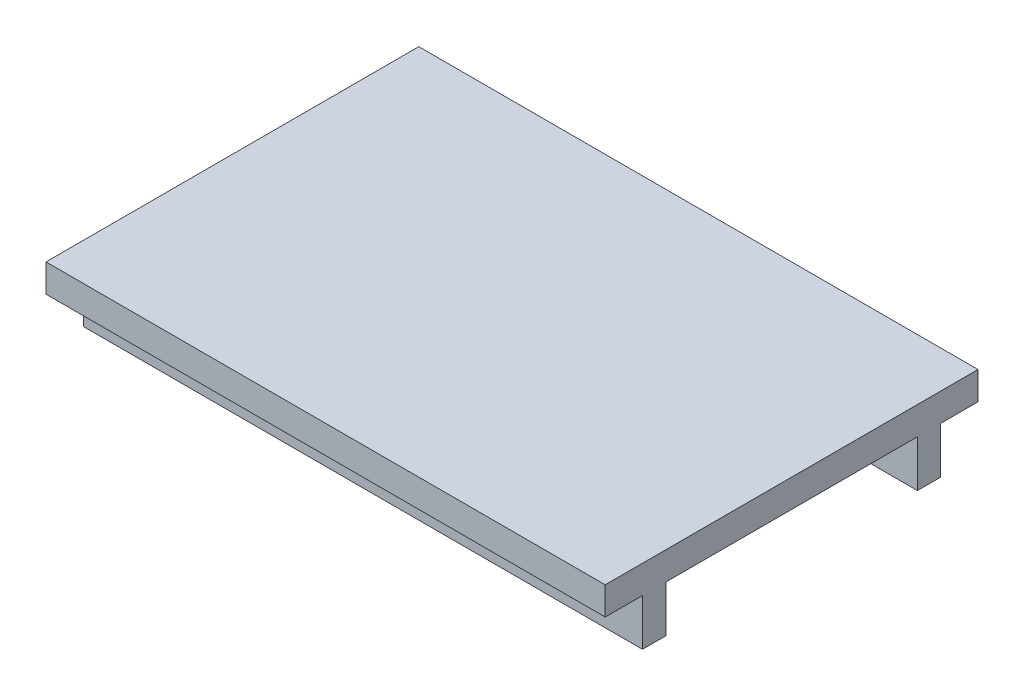
from build123d import *

# Parameters (mm, degrees)
SKETCH_1_W          = 120
SKETCH_1_H          = 80
EXTRUDE_1_DEPTH     = 6
SKETCH_10_W         = 120
SKETCH_10_H         = 5
EXTRUDE_3_DEPTH     = 10
SKETCH_11_R         = 2.5
CUT_EXTRUDE_1_DEPTH = 5


with BuildPart() as part:
    # 草圖1 → 填料-伸長1 (new body)
    with BuildSketch(Plane(origin=(0, 0, 0), x_dir=(1, 0, 0), z_dir=(0, 1, 0))):
        Rectangle(SKETCH_1_W, SKETCH_1_H)
    extrude(amount=EXTRUDE_1_DEPTH)

    # 草圖10 → 填料-伸長3 (add)
    with BuildSketch(Plane.XZ):
        with Locations((0, 29.5)):
            Rectangle(SKETCH_10_W, SKETCH_10_H)
    extrude_3 = extrude(amount=EXTRUDE_3_DEPTH)

    # 草圖11 → 除料-伸長1 (cut)
    with BuildSketch(Plane.XY.offset(32)):
        with Locations((-45, -5)):
            Circle(SKETCH_11_R)
        with BuildLine():
            Line((-20, -2.5), (50, -2.5))
            ThreePointArc((50, -2.5), (52.5, -5), (50, -7.5))
            Line((50, -7.5), (-20, -7.5))
            ThreePointArc((-20, -7.5), (-22.5, -5), (-20, -2.5))
        make_face()
    cut_extrude_1 = extrude(amount=-CUT_EXTRUDE_1_DEPTH, mode=Mode.SUBTRACT)

    # 鏡射3: 填料-伸長3, 除料-伸長1 across plane
    add(extrude_3.mirror(Plane.XY))
    add(cut_extrude_1.mirror(Plane.XY), mode=Mode.SUBTRACT)


solid = part.part
